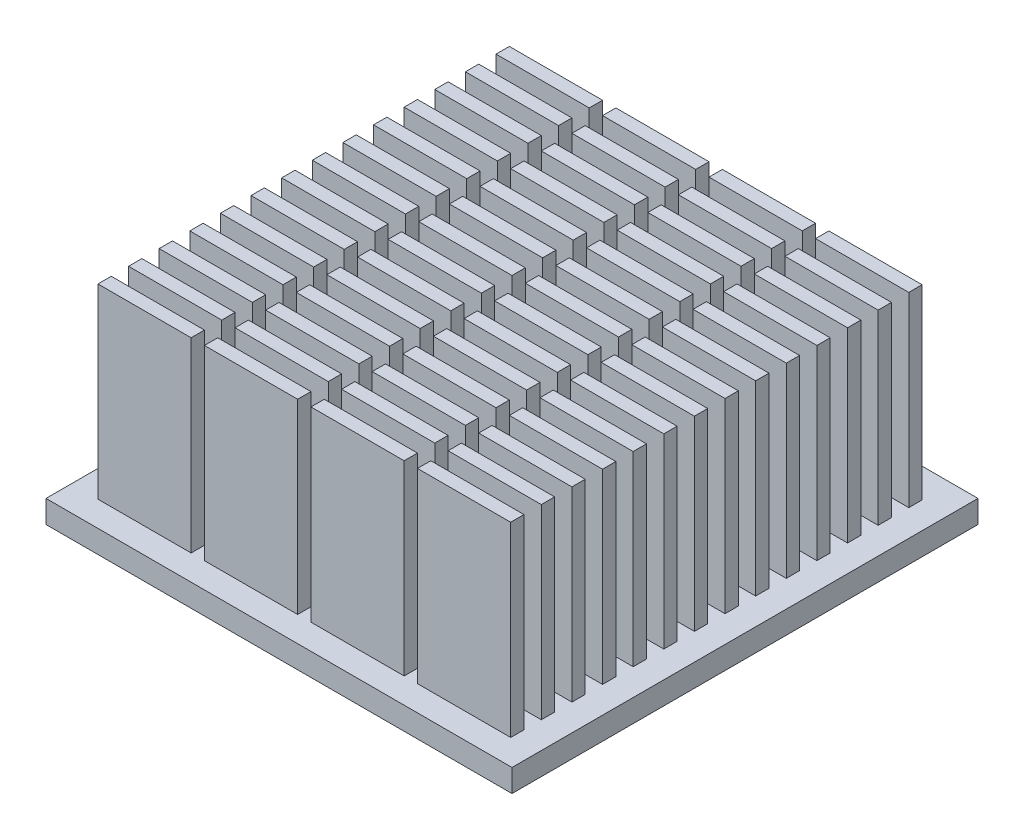
from build123d import *

# Parameters (mm, degrees)
SKETCH1_W           = 35
SKETCH1_H           = 35
BOSS_EXTRUDE1_DEPTH = 1.7
SKETCH2_W           = 7
SKETCH2_H           = 1
BOSS_EXTRUDE2_DEPTH = 14


with BuildPart() as part:
    # Sketch1 → Boss-Extrude1 (new body)
    with BuildSketch(Plane(origin=(0, 0, 0), x_dir=(1, 0, 0), z_dir=(0, 1, 0))):
        Rectangle(SKETCH1_W, SKETCH1_H)
    extrude(amount=BOSS_EXTRUDE1_DEPTH)

    # Sketch2 → Boss-Extrude2 (add)
    with BuildSketch(Plane(origin=(0, 1.7, 0), x_dir=(1, 0, 0), z_dir=(0, 1, 0))):
        with Locations((-12, -1.3)):
            Rectangle(SKETCH2_W, SKETCH2_H)
        with Locations((-12, 1)):
            Rectangle(SKETCH2_W, SKETCH2_H)
        with Locations((-4, 1)):
            Rectangle(SKETCH2_W, SKETCH2_H)
        with Locations((4, 1)):
            Rectangle(SKETCH2_W, SKETCH2_H)
        with Locations((12, 1)):
            Rectangle(SKETCH2_W, SKETCH2_H)
        with Locations((-4, -1.3)):
            Rectangle(SKETCH2_W, SKETCH2_H)
        with Locations((4, -1.3)):
            Rectangle(SKETCH2_W, SKETCH2_H)
        with Locations((12, -1.3)):
            Rectangle(SKETCH2_W, SKETCH2_H)
        with Locations((-12, -3.6)):
            Rectangle(SKETCH2_W, SKETCH2_H)
        with Locations((-4, -3.6)):
            Rectangle(SKETCH2_W, SKETCH2_H)
        with Locations((4, -3.6)):
            Rectangle(SKETCH2_W, SKETCH2_H)
        with Locations((12, -3.6)):
            Rectangle(SKETCH2_W, SKETCH2_H)
        with Locations((-12, -5.9)):
            Rectangle(SKETCH2_W, SKETCH2_H)
        with Locations((-4, -5.9)):
            Rectangle(SKETCH2_W, SKETCH2_H)
        with Locations((4, -5.9)):
            Rectangle(SKETCH2_W, SKETCH2_H)
        with Locations((12, -5.9)):
            Rectangle(SKETCH2_W, SKETCH2_H)
        with Locations((-12, -8.2)):
            Rectangle(SKETCH2_W, SKETCH2_H)
        with Locations((-4, -8.2)):
            Rectangle(SKETCH2_W, SKETCH2_H)
        with Locations((4, -8.2)):
            Rectangle(SKETCH2_W, SKETCH2_H)
        with Locations((12, -8.2)):
            Rectangle(SKETCH2_W, SKETCH2_H)
        with Locations((-12, -10.5)):
            Rectangle(SKETCH2_W, SKETCH2_H)
        with Locations((-4, -10.5)):
            Rectangle(SKETCH2_W, SKETCH2_H)
        with Locations((4, -10.5)):
            Rectangle(SKETCH2_W, SKETCH2_H)
        with Locations((12, -10.5)):
            Rectangle(SKETCH2_W, SKETCH2_H)
        with Locations((-12, -12.8)):
            Rectangle(SKETCH2_W, SKETCH2_H)
        with Locations((-4, -12.8)):
            Rectangle(SKETCH2_W, SKETCH2_H)
        with Locations((4, -12.8)):
            Rectangle(SKETCH2_W, SKETCH2_H)
        with Locations((12, -12.8)):
            Rectangle(SKETCH2_W, SKETCH2_H)
        with Locations((-12, -15.1)):
            Rectangle(SKETCH2_W, SKETCH2_H)
        with Locations((-4, -15.1)):
            Rectangle(SKETCH2_W, SKETCH2_H)
        with Locations((4, -15.1)):
            Rectangle(SKETCH2_W, SKETCH2_H)
        with Locations((12, -15.1)):
            Rectangle(SKETCH2_W, SKETCH2_H)
        with Locations((-12, 3.3)):
            Rectangle(SKETCH2_W, SKETCH2_H)
        with Locations((-4, 3.3)):
            Rectangle(SKETCH2_W, SKETCH2_H)
        with Locations((4, 3.3)):
            Rectangle(SKETCH2_W, SKETCH2_H)
        with Locations((12, 3.3)):
            Rectangle(SKETCH2_W, SKETCH2_H)
        with Locations((-12, 5.6)):
            Rectangle(SKETCH2_W, SKETCH2_H)
        with Locations((-4, 5.6)):
            Rectangle(SKETCH2_W, SKETCH2_H)
        with Locations((4, 5.6)):
            Rectangle(SKETCH2_W, SKETCH2_H)
        with Locations((12, 5.6)):
            Rectangle(SKETCH2_W, SKETCH2_H)
        with Locations((-12, 7.9)):
            Rectangle(SKETCH2_W, SKETCH2_H)
        with Locations((-4, 7.9)):
            Rectangle(SKETCH2_W, SKETCH2_H)
        with Locations((4, 7.9)):
            Rectangle(SKETCH2_W, SKETCH2_H)
        with Locations((12, 7.9)):
            Rectangle(SKETCH2_W, SKETCH2_H)
        with Locations((-12, 10.2)):
            Rectangle(SKETCH2_W, SKETCH2_H)
        with Locations((-4, 10.2)):
            Rectangle(SKETCH2_W, SKETCH2_H)
        with Locations((4, 10.2)):
            Rectangle(SKETCH2_W, SKETCH2_H)
        with Locations((12, 10.2)):
            Rectangle(SKETCH2_W, SKETCH2_H)
        with Locations((-12, 12.5)):
            Rectangle(SKETCH2_W, SKETCH2_H)
        with Locations((-4, 12.5)):
            Rectangle(SKETCH2_W, SKETCH2_H)
        with Locations((4, 12.5)):
            Rectangle(SKETCH2_W, SKETCH2_H)
        with Locations((12, 12.5)):
            Rectangle(SKETCH2_W, SKETCH2_H)
        with Locations((-12, 14.8)):
            Rectangle(SKETCH2_W, SKETCH2_H)
        with Locations((-4, 14.8)):
            Rectangle(SKETCH2_W, SKETCH2_H)
        with Locations((4, 14.8)):
            Rectangle(SKETCH2_W, SKETCH2_H)
        with Locations((12, 14.8)):
            Rectangle(SKETCH2_W, SKETCH2_H)
    extrude(amount=BOSS_EXTRUDE2_DEPTH)


solid = part.part
